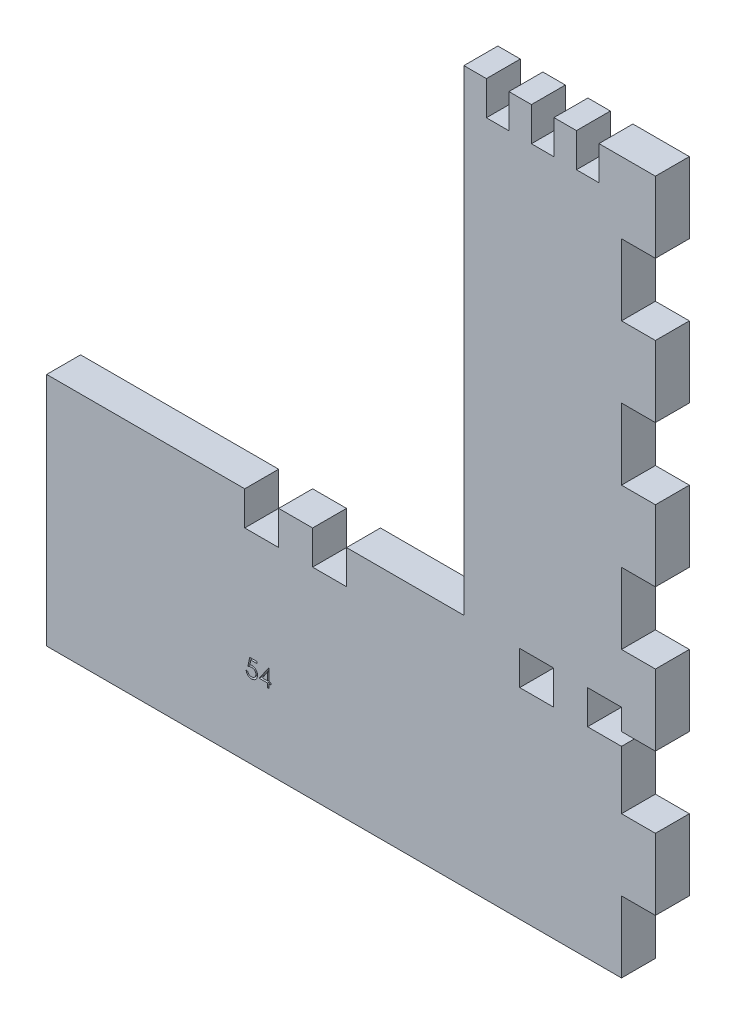
from build123d import *

# Parameters (mm, degrees)
SKETCH6_W           = 6.2
SKETCH6_H           = 6.2
BOSS_EXTRUDE4_DEPTH = 6.2
CUT_EXTRUDE3_DEPTH  = 1


with BuildPart() as part:
    # Sketch6 → Boss-Extrude4 (new body)
    with BuildSketch(Plane.XY):
        Polygon((157.908027241, 124.79254071), (153.794027241, 124.79254071), (153.794027241, 37.79254071), (132.344027241, 37.79254071), (132.344027241, 31.59254071), (126.144027241, 31.59254071), (126.144027241, 37.79254071), (119.944027241, 37.79254071), (119.944027241, 31.59254071), (113.744027241, 31.59254071), (113.744027241, 37.79254071), (77.544027241, 37.79254071), (77.544027241, -5.20745929), (182.594027241, -5.20745929), (182.594027241, 7.79254071), (188.794027241, 7.79254071), (188.794027241, 20.79254071), (182.594027241, 20.79254071), (182.594027241, 31.453899243), (176.394027241, 31.453899243), (176.394027241, 37.653899243), (182.594027241, 37.653899243), (182.594027241, 33.79254071), (188.794027241, 33.79254071), (188.794027241, 46.79254071), (182.594027241, 46.79254071), (182.594027241, 59.79254071), (188.794027241, 59.79254071), (188.794027241, 72.79254071), (182.594027241, 72.79254071), (182.594027241, 85.79254071), (188.794027241, 85.79254071), (188.794027241, 98.79254071), (182.594027241, 98.79254071), (182.594027241, 111.79254071), (188.794027241, 111.79254071), (188.794027241, 124.79254071), (178.478027241, 124.79254071), (178.478027241, 118.59254071), (174.364027241, 118.59254071), (174.364027241, 124.79254071), (170.250027241, 124.79254071), (170.250027241, 118.59254071), (166.136027241, 118.59254071), (166.136027241, 124.79254071), (162.022027241, 124.79254071), (162.022027241, 118.59254071), (157.908027241, 118.59254071), align=None)
        with Locations((167.094027241, 34.553899243)):
            Rectangle(SKETCH6_W, SKETCH6_H, mode=Mode.SUBTRACT)
    extrude(amount=BOSS_EXTRUDE4_DEPTH)

    # Sketch7 → Cut-Extrude3 (cut)
    with BuildSketch(Plane.XY.offset(6.2)):
        with BuildLine():
            Line((115.946331614, 11.576783669), (115.946331614, 11.251142644))
            Line((115.946331614, 11.251142644), (114.866373682, 11.251142644))
            Line((114.866373682, 11.251142644), (114.69528494, 10.416051498))
            add(Edge.make_bspline(
                [(114.69528494, 10.416051498), (114.728899911, 10.425331816), (114.794023603, 10.443310964), (114.890144334, 10.463273342), (114.981395832, 10.475306994), (115.040609919, 10.476950112), (115.069263305, 10.477745208)],
                knots=[0, 0, 0, 0, 0.000104595, 0.000202637, 0.000294305, 0.000380252, 0.000380252, 0.000380252, 0.000380252], degree=3))
            add(Edge.make_bspline(
                [(115.069263305, 10.477745208), (115.10471784, 10.476977823), (115.174430315, 10.475468954), (115.276428503, 10.460980204), (115.37379477, 10.43817471), (115.466325492, 10.40631538), (115.554191848, 10.365575836), (115.636585422, 10.314685176), (115.714742957, 10.255237083), (115.78726231, 10.186888393), (115.853052218, 10.111666641), (115.910897081, 10.030787715), (115.960030287, 9.945037622), (115.999546115, 9.853597069), (116.031100475, 9.75747698), (116.052102642, 9.655665995), (116.0660878, 9.549123772), (116.06765025, 9.476276054), (116.068446999, 9.439128421)],
                knots=[0, 0, 0, 0, 0.000106308, 0.000209029, 0.000308378, 0.000405929, 0.000502102, 0.000598312, 0.00069588, 0.000796219, 0.000896736, 0.000995218, 0.001094066, 0.001192613, 0.001293582, 0.001396995, 0.001504047, 0.001615439, 0.001615439, 0.001615439, 0.001615439], degree=3))
            add(Edge.make_bspline(
                [(116.068446999, 9.439128421), (116.067843681, 9.413254692), (116.066645197, 9.361856897), (116.060550479, 9.285526086), (116.048815936, 9.21081123), (116.033060929, 9.137702418), (116.012611736, 9.066338059), (115.987856666, 8.996513887), (115.957561698, 8.928664494), (115.924331807, 8.862147885), (115.886915359, 8.798467811), (115.845387713, 8.738914802), (115.801513304, 8.682595489), (115.754304332, 8.630113888), (115.703322001, 8.581814865), (115.649183746, 8.537411781), (115.592321565, 8.496153717), (115.531855738, 8.459715426), (115.469133628, 8.426184744), (115.40324946, 8.398676964), (115.335702967, 8.374083842), (115.265521973, 8.354480913), (115.192865443, 8.339120668), (115.117613611, 8.32868798), (115.040161146, 8.321089354), (114.987660242, 8.320613688), (114.961140308, 8.320373413)],
                knots=[0, 0, 0, 0, 7.7636e-05, 0.000154223, 0.000229512, 0.000304362, 0.000378447, 0.000452077, 0.000526407, 0.000601214, 0.00067506, 0.000747747, 0.00081887, 0.000889121, 0.000959302, 0.001029336, 0.001099058, 0.00116985, 0.001240974, 0.00131221, 0.00138383, 0.001456517, 0.001530612, 0.001606437, 0.001684346, 0.001763871, 0.001763871, 0.001763871, 0.001763871], degree=3))
            add(Edge.make_bspline(
                [(114.961140308, 8.320373413), (114.929504444, 8.321000102), (114.867264619, 8.322233038), (114.776078105, 8.335131235), (114.688344141, 8.353604216), (114.604768978, 8.38139569), (114.524603617, 8.41621845), (114.448927295, 8.460229548), (114.375806341, 8.51010345), (114.308213279, 8.568959198), (114.245478804, 8.633289853), (114.189320757, 8.703101427), (114.139306727, 8.777241707), (114.096237628, 8.856070747), (114.059500137, 8.939381414), (114.030639398, 9.02748585), (114.007345461, 9.119923711), (113.997490787, 9.183562967), (113.99248546, 9.215886233)],
                knots=[0, 0, 0, 0, 9.4843e-05, 0.000186593, 0.000275792, 0.000363484, 0.000450342, 0.000537514, 0.000625728, 0.000715478, 0.000805885, 0.000894984, 0.00098389, 0.001073836, 0.001164117, 0.001256635, 0.001351658, 0.001449737, 0.001449737, 0.001449737, 0.001449737], degree=3))
            Line((113.99248546, 9.215886233), (114.277421358, 9.215886233))
            add(Edge.make_bspline(
                [(114.277421358, 9.215886233), (114.284432264, 9.185609023), (114.297907613, 9.127414543), (114.327485686, 9.045652541), (114.36364973, 8.972791531), (114.406652246, 8.907867695), (114.457951202, 8.851253818), (114.516488613, 8.800801198), (114.582118333, 8.755285188), (114.655046477, 8.717345963), (114.731984056, 8.684989308), (114.812508596, 8.663443128), (114.894427539, 8.648293032), (114.949834347, 8.646776506), (114.977676767, 8.646014439)],
                knots=[0, 0, 0, 0, 9.3172e-05, 0.000179081, 0.000260145, 0.000336703, 0.000411917, 0.000488562, 0.000568128, 0.000650923, 0.00073478, 0.000817953, 0.000900557, 0.000983994, 0.000983994, 0.000983994, 0.000983994], degree=3))
            add(Edge.make_bspline(
                [(114.977676767, 8.646014439), (115.004853355, 8.646759001), (115.058364281, 8.648225052), (115.137114611, 8.659509013), (115.213144861, 8.676887667), (115.28570482, 8.702895321), (115.356064217, 8.734504458), (115.42244328, 8.77506742), (115.486762318, 8.821749008), (115.547022125, 8.875231094), (115.602212197, 8.934167888), (115.650976678, 8.997193809), (115.691595736, 9.064428377), (115.725825963, 9.134707595), (115.751818598, 9.208801714), (115.770361488, 9.286363495), (115.781249978, 9.367584512), (115.782747834, 9.4229831), (115.783511101, 9.451212756)],
                knots=[0, 0, 0, 0, 8.15e-05, 0.000160473, 0.000238226, 0.000315066, 0.000391338, 0.000469218, 0.000547964, 0.000629516, 0.000710512, 0.000789892, 0.000868102, 0.000945761, 0.001024012, 0.00110315, 0.001184644, 0.001269321, 0.001269321, 0.001269321, 0.001269321], degree=3))
            add(Edge.make_bspline(
                [(115.783511101, 9.451212756), (115.782913767, 9.476681473), (115.781744568, 9.526532864), (115.772191837, 9.59946643), (115.755575726, 9.668475547), (115.732512635, 9.733893459), (115.70323051, 9.795781868), (115.66744707, 9.854204644), (115.624490773, 9.908391764), (115.575421703, 9.95836858), (115.521666194, 10.004492145), (115.46229937, 10.043811424), (115.39856358, 10.076889406), (115.331226729, 10.105435376), (115.258687142, 10.125937481), (115.18238134, 10.141329777), (115.101485326, 10.150233713), (115.046176202, 10.15146914), (115.017745877, 10.152104182)],
                knots=[0, 0, 0, 0, 7.6388e-05, 0.000149519, 0.000220172, 0.000288967, 0.000357247, 0.000425206, 0.000494043, 0.000564207, 0.000635056, 0.000706145, 0.000777268, 0.000850264, 0.000925136, 0.001002969, 0.001083601, 0.001168886, 0.001168886, 0.001168886, 0.001168886], degree=3))
            add(Edge.make_bspline(
                [(115.017745877, 10.152104182), (114.993136063, 10.151577503), (114.942323041, 10.150490044), (114.864378762, 10.142483151), (114.782471271, 10.129566076), (114.69691455, 10.111798552), (114.60745166, 10.088547504), (114.514271397, 10.060685064), (114.417177841, 10.027372965), (114.351756762, 10.002215885), (114.318126486, 9.989283669)],
                knots=[0, 0, 0, 0, 7.3822e-05, 0.000152423, 0.000234822, 0.000322511, 0.00041445, 0.000512043, 0.000614219, 0.000722306, 0.000722306, 0.000722306, 0.000722306], degree=3))
            Line((114.318126486, 9.989283669), (114.643767512, 11.576783669))
            Line((114.643767512, 11.576783669), (115.946331614, 11.576783669))
        make_face()
        Polygon((118.127236061, 11.658193926), (118.185113666, 11.658193926), (118.185113666, 9.460117003), (118.551459819, 9.460117003), (118.551459819, 9.134475977), (118.185113666, 9.134475977), (118.185113666, 8.401783669), (117.900177768, 8.401783669), (117.900177768, 9.134475977), (116.394088025, 9.134475977), align=None)
        Polygon((117.900177768, 9.460117003), (117.900177768, 10.839003221), (116.953783537, 9.460117003), align=None, mode=Mode.SUBTRACT)
    extrude(amount=-CUT_EXTRUDE3_DEPTH, mode=Mode.SUBTRACT)


solid = part.part
